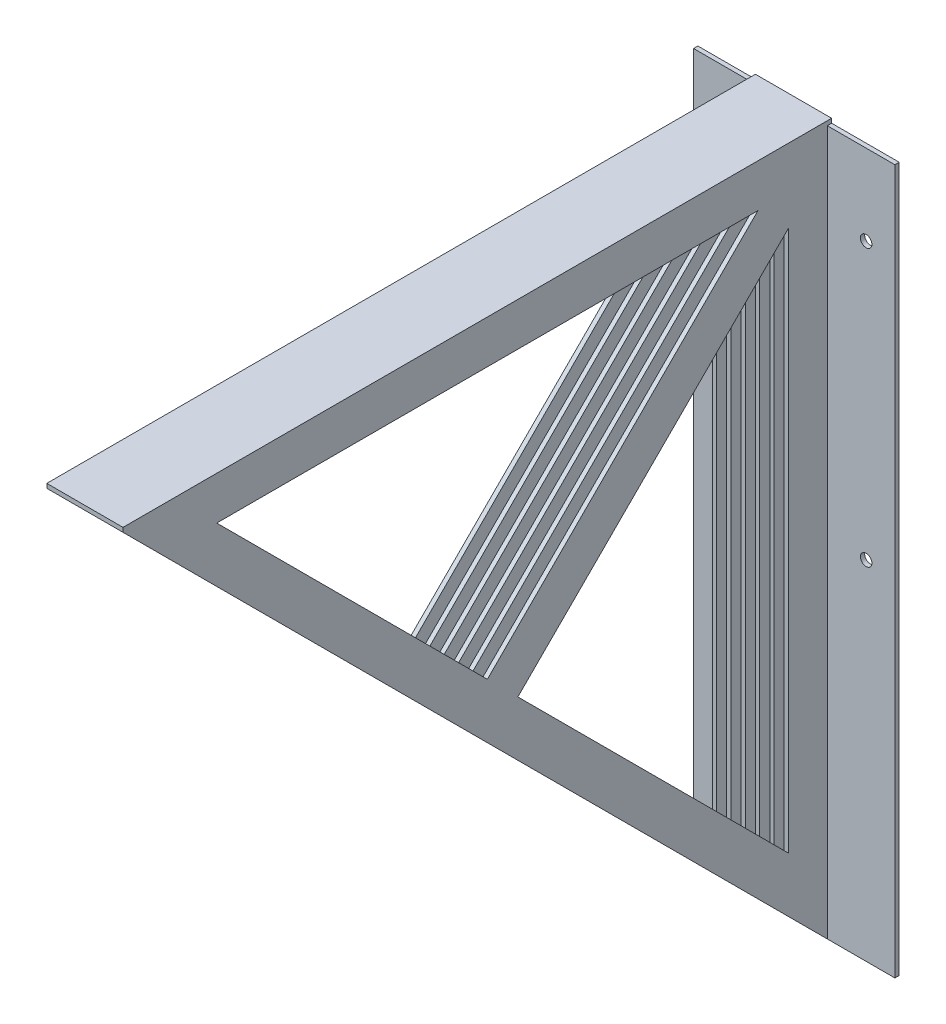
from build123d import *

# Parameters (mm, degrees)
BOSS_EXTRUDE1_DEPTH     = 1.5
CUT_EXTRUDE2_DEPTH      = 1.5
SKETCH4_W               = 50
SKETCH4_H               = 244.878679656
BOSS_EXTRUDE2_DEPTH     = 1.5
LPATTERN1_COUNT         = 6
LPATTERN1_PITCH         = 5
CUT_EXTRUDE3_DEPTH      = 11
CUT_EXTRUDE3_DEPTH_BACK = 41
SKETCH6_W               = 26.5
SKETCH6_H               = 246.378679656
BOSS_EXTRUDE3_DEPTH     = 1.5
SKETCH8_W               = 70
SKETCH8_H               = 244.878679656
BOSS_EXTRUDE9_DEPTH     = 1.5
SKETCH9_R               = 2
CUT_EXTRUDE4_DEPTH      = 1.5


with BuildPart() as part:
    # Sketch2 → Boss-Extrude1 (new body)
    with BuildSketch(Plane(origin=(0, 0, 0), x_dir=(0, 0, -1), z_dir=(1, 0, 0))):
        Polygon((0, 0), (-250, 0), (0, -250), align=None)
        Polygon((-213.786796564, -15), (-25.606601718, -15), (-119.696699141, -109.090097423), align=None, mode=Mode.SUBTRACT)
        Polygon((-109.090097423, -119.696699141), (-15, -25.606601718), (-15, -213.786796564), align=None, mode=Mode.SUBTRACT)
    boss_extrude1 = extrude(amount=BOSS_EXTRUDE1_DEPTH)

    # Sketch3 → Cut-Extrude2 (cut)
    with BuildSketch(Plane(origin=(1.5, 0, 0), x_dir=(0, 0, -1), z_dir=(1, 0, 0))):
        Polygon((6, -264.485281374), (6, 6), (-264.485281374, 6), align=None)
        Polygon((-1.5, -246.378679656), (-1.5, -1.5), (-246.378679656, -1.5), align=None, mode=Mode.SUBTRACT)
    extrude(amount=-CUT_EXTRUDE2_DEPTH, mode=Mode.SUBTRACT)

    # Sketch4 → Boss-Extrude2 (add)
    with BuildSketch(Plane(origin=(0, 0, 1.5), x_dir=(-1, 0, 0), z_dir=(0, 0, -1))):
        with Locations((-15, -123.939339828)):
            Rectangle(SKETCH4_W, SKETCH4_H)
    extrude(amount=BOSS_EXTRUDE2_DEPTH)

    # LPattern1: Boss-Extrude1 ×6
    with Locations(*[(i * LPATTERN1_PITCH, 0, 0) for i in range(1, LPATTERN1_COUNT)]):
        add(boss_extrude1)

    # Sketch5 → Cut-Extrude3 (cut, two sides)
    with BuildSketch(Plane.ZY) as cut_extrude3_sk:
        Polygon((0, -246.378679656), (0, -250), (250, 0), (0, 0), (0, -1.5), (246.378679656, -1.5), (1.5, -246.378679656), align=None)
    extrude(amount=CUT_EXTRUDE3_DEPTH, mode=Mode.SUBTRACT)
    extrude(cut_extrude3_sk.sketch, amount=-CUT_EXTRUDE3_DEPTH_BACK, mode=Mode.SUBTRACT)

    # Sketch6 → Boss-Extrude3 (add)
    with BuildSketch(Plane(origin=(0, -1.5, 0), x_dir=(1, 0, 0), z_dir=(0, 1, 0))):
        with Locations((13.25, -123.189339828)):
            Rectangle(SKETCH6_W, SKETCH6_H)
    extrude(amount=BOSS_EXTRUDE3_DEPTH)

    # Sketch8 → Boss-Extrude9 (add)
    with BuildSketch(Plane.XY.offset(1.5)):
        with Locations((15, -123.939339828)):
            Rectangle(SKETCH8_W, SKETCH8_H)
    extrude(amount=-BOSS_EXTRUDE9_DEPTH)

    # Sketch9 → Cut-Extrude4 (cut)
    with BuildSketch(Plane.XY.offset(1.5)):
        with Locations((-10, -29.5)):
            Circle(SKETCH9_R)
        with Locations((-10, -125.5)):
            Circle(SKETCH9_R)
        with Locations((40, -29.5)):
            Circle(SKETCH9_R)
        with Locations((40, -125.5)):
            Circle(SKETCH9_R)
    extrude(amount=-CUT_EXTRUDE4_DEPTH, mode=Mode.SUBTRACT)


solid = part.part
